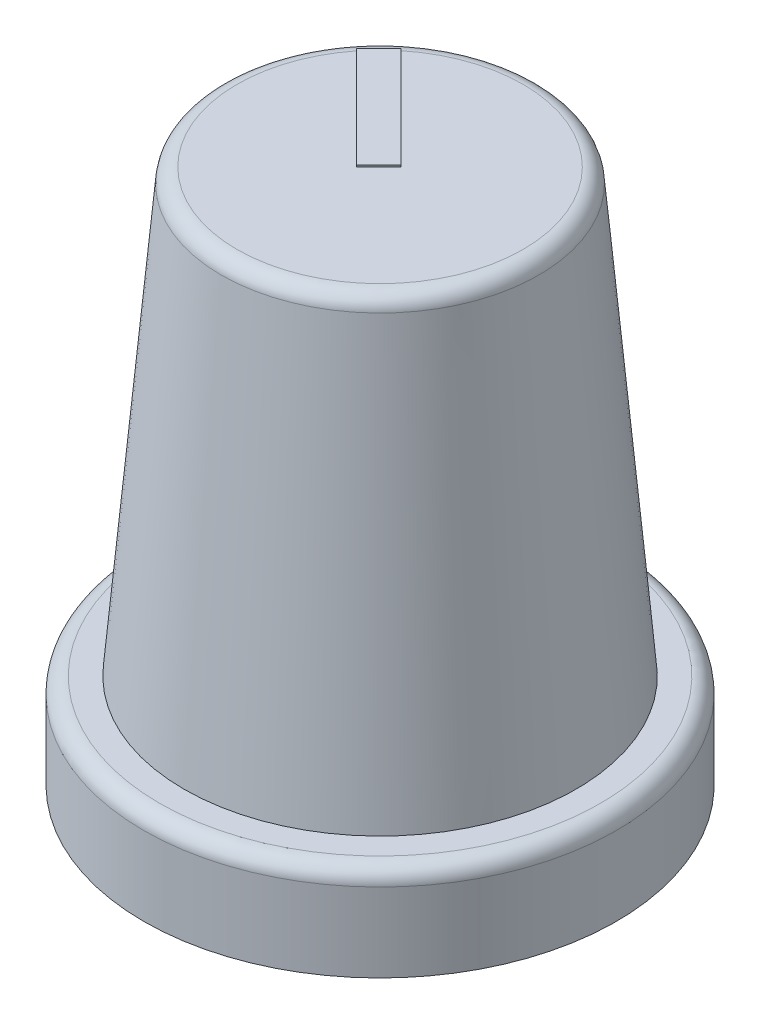
from build123d import *

# Parameters (mm, degrees)
SKETCH1_R           = 7.5
BOSS_EXTRUDE1_DEPTH = 3
SKETCH2_R           = 5
BOSS_EXTRUDE2_DEPTH = 14
BOSS_EXTRUDE2_TAPER = -5
SKETCH4_R           = 6.5
CUT_EXTRUDE1_DEPTH  = 2
SKETCH5_R           = 5.5
CUT_EXTRUDE2_DEPTH  = 14
CUT_EXTRUDE2_TAPER  = 5
FILLET1_R           = 0.5
FILLET2_R           = 0.5
BOSS_EXTRUDE3_DEPTH = 0.05


with BuildPart() as part:
    # Sketch1 → Boss-Extrude1 (new body)
    with BuildSketch(Plane(origin=(0, 0, 0), x_dir=(1, 0, 0), z_dir=(0, 1, 0))):
        Circle(SKETCH1_R)
    extrude(amount=BOSS_EXTRUDE1_DEPTH)

    # Sketch2 → Boss-Extrude2 (add)
    with BuildSketch(Plane(origin=(0, 17, 0), x_dir=(1, 0, 0), z_dir=(0, 1, 0))):
        Circle(SKETCH2_R)
    extrude(amount=-BOSS_EXTRUDE2_DEPTH, taper=BOSS_EXTRUDE2_TAPER)

    # Sketch4 → Cut-Extrude1 (cut)
    with BuildSketch(Plane.XZ):
        Circle(SKETCH4_R)
    extrude(amount=-CUT_EXTRUDE1_DEPTH, mode=Mode.SUBTRACT)

    # Sketch5 → Cut-Extrude2 (cut)
    with BuildSketch(Plane.XZ.offset(-2)):
        Circle(SKETCH5_R)
    extrude(amount=-CUT_EXTRUDE2_DEPTH, taper=CUT_EXTRUDE2_TAPER, mode=Mode.SUBTRACT)

    # Fillet1
    fillet1_edges = [part.edges().sort_by_distance(p)[0] for p in [
        (-7.5, 3, 0),
    ]]
    fillet(fillet1_edges, radius=FILLET1_R)

    # Fillet2
    fillet2_edges = [part.edges().sort_by_distance(p)[0] for p in [
        (-5, 17, 0),
    ]]
    fillet(fillet2_edges, radius=FILLET2_R)

    # Sketch7 → Boss-Extrude3 (add)
    with BuildSketch(Plane(origin=(0, 17, 0), x_dir=(1, 0, 0), z_dir=(0, 1, 0))):
        Polygon((-0.372418319, -0.372418319), (0.334688462, 0.334688462), (-2.876818043, 3.546194967), (-3.583924824, 2.839088186), align=None)
    extrude(amount=BOSS_EXTRUDE3_DEPTH)


solid = part.part
